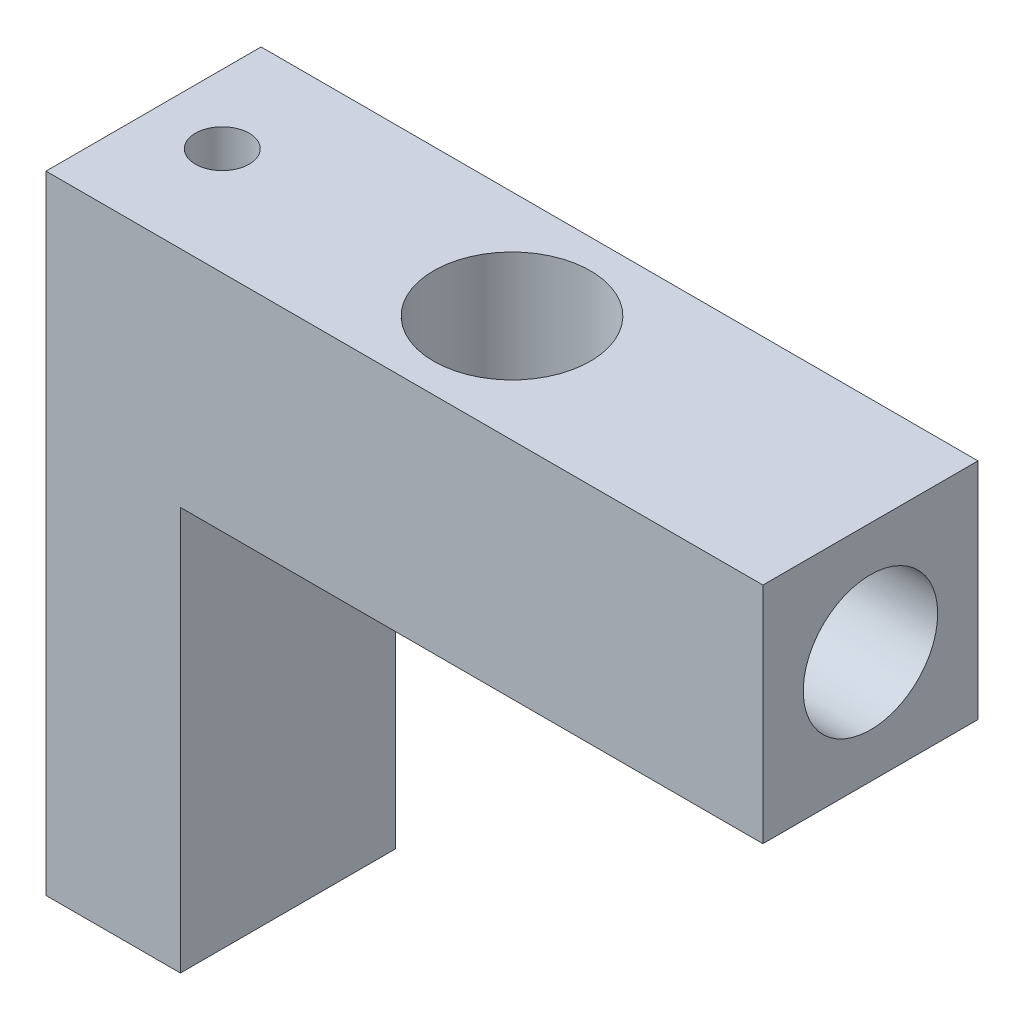
from build123d import *

# Parameters (mm, degrees)
SKETCH_1_W          = 16
SKETCH_1_H          = 4.8
SKETCH_1_R          = 1.75
EXTRUDE_1_DEPTH     = 5
SKETCH_2_R          = 1.5
CUT_EXTRUDE_1_DEPTH = 3
SKETCH_3_R          = 0.55
CUT_EXTRUDE_2_DEPTH = 4
SKETCH_5_W          = 3
SKETCH_5_H          = 4.8
EXTRUDE_2_DEPTH     = 9
SKETCH_6_R          = 0.6
CUT_EXTRUDE_3_DEPTH = 15.0000001


with BuildPart() as part:
    # 草图1 → 凸台-拉伸1 (new body)
    with BuildSketch(Plane(origin=(0, 0, 0), x_dir=(1, 0, 0), z_dir=(0, 1, 0))):
        Rectangle(SKETCH_1_W, SKETCH_1_H)
        Circle(SKETCH_1_R, mode=Mode.SUBTRACT)
    extrude(amount=EXTRUDE_1_DEPTH)

    # 草图2 → 切除-拉伸1 (cut)
    with BuildSketch(Plane(origin=(8, 0, 0), x_dir=(0, 0, -1), z_dir=(1, 0, 0))):
        with Locations((0, 2.5)):
            Circle(SKETCH_2_R)
    extrude(amount=-CUT_EXTRUDE_1_DEPTH, mode=Mode.SUBTRACT)

    # 草图3 → 切除-拉伸2 (cut)
    with BuildSketch(Plane(origin=(5, 0, 0), x_dir=(0, 0, -1), z_dir=(1, 0, 0))):
        with Locations((0, 2.5)):
            Circle(SKETCH_3_R)
    extrude(amount=-CUT_EXTRUDE_2_DEPTH, mode=Mode.SUBTRACT)

    # 草图5 → 凸台-拉伸2 (add)
    with BuildSketch(Plane.XZ):
        with Locations((-6.5, 0)):
            Rectangle(SKETCH_5_W, SKETCH_5_H)
    extrude(amount=EXTRUDE_2_DEPTH)

    # 草图6 → 切除-拉伸3 (cut, through all)
    with BuildSketch(Plane.XZ.offset(9)):
        with Locations((-6.465889023, 0)):
            Circle(SKETCH_6_R)
    extrude(amount=-CUT_EXTRUDE_3_DEPTH, mode=Mode.SUBTRACT)


solid = part.part
